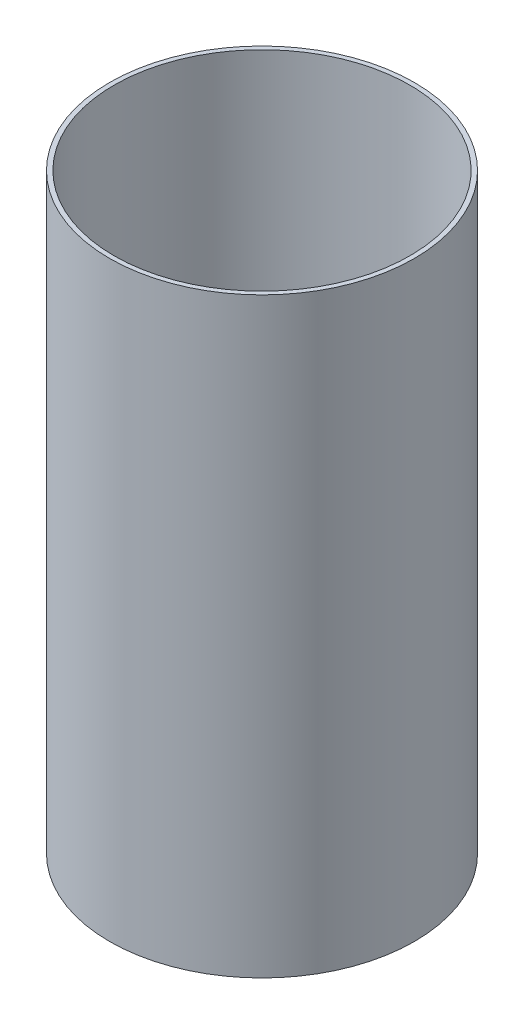
from build123d import *

# Parameters (mm, degrees)
SKETCH1_R           = 65.4431
SKETCH1_R_2         = 63.5
BOSS_EXTRUDE2_DEPTH = 254


with BuildPart() as part:
    # Sketch1 → Boss-Extrude2 (new body)
    with BuildSketch(Plane(origin=(0, 0, 0), x_dir=(1, 0, 0), z_dir=(0, 1, 0))):
        Circle(SKETCH1_R)
        Circle(SKETCH1_R_2, mode=Mode.SUBTRACT)
    extrude(amount=BOSS_EXTRUDE2_DEPTH)


solid = part.part
